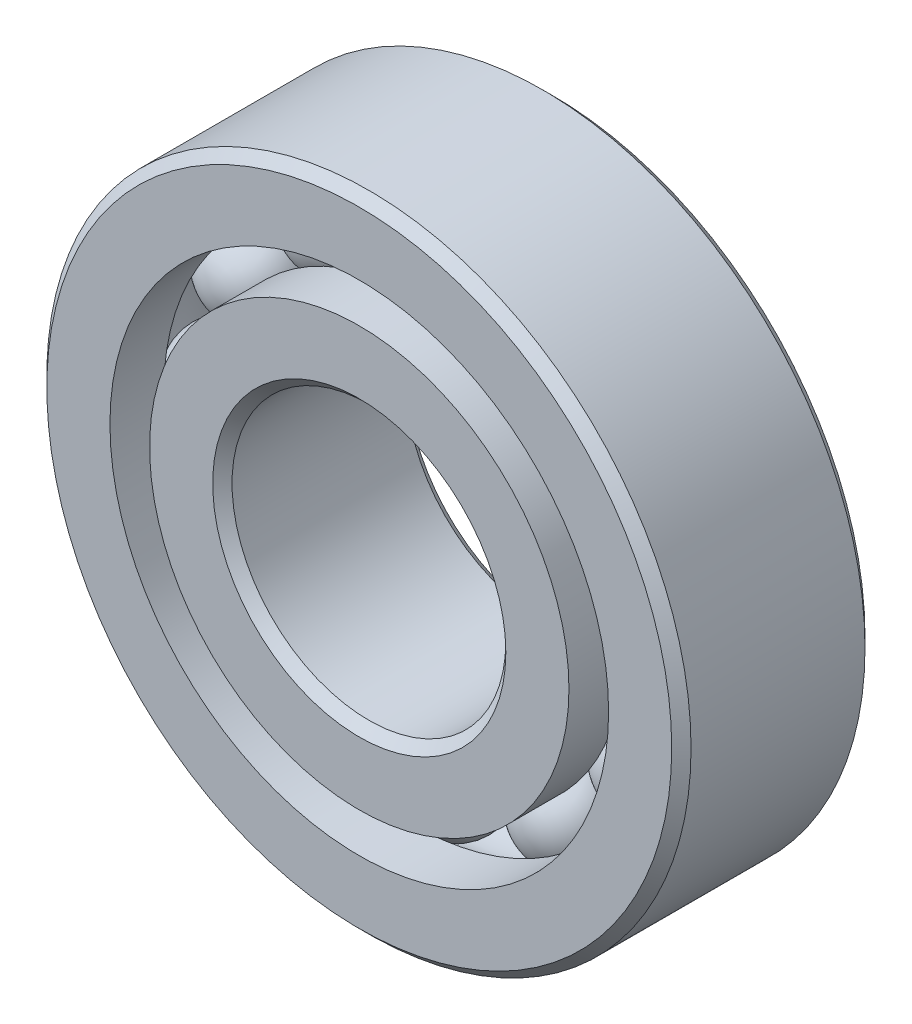
from build123d import *

# Parameters (mm, degrees)
CIRPATTERN1_COUNT = 12


with BuildPart() as part:
    # Sketch1 → Revolve1 (revolve)
    with BuildSketch(Plane(origin=(0, 0, 0), x_dir=(0, 0, -1), z_dir=(1, 0, 0))):
        with BuildLine():
            Line((5.4, 20), (-5.4, 20))
            Line((-5.4, 20), (-6, 19.4))
            Line((-6, 19.4), (-6, 15.480769231))
            Line((-6, 15.480769231), (-2.666666667, 15.480769231))
            ThreePointArc((-2.666666667, 15.480769231), (0, 17.186988936), (2.666666667, 15.480769231))
            Line((2.666666667, 15.480769231), (6, 15.480769231))
            Line((6, 15.480769231), (6, 19.4))
            Line((6, 19.4), (5.4, 20))
        make_face()
    revolve(axis=Axis((0, 0, 6), (0, 0, -1)))


with BuildPart() as body_2:
    # Sketch3 → Revolve3 (revolve)
    with BuildSketch(Plane(origin=(0, 0, 0), x_dir=(0, 0, -1), z_dir=(1, 0, 0))):
        with BuildLine():
            Line((-6, 13.019230769), (-2.666666667, 13.019230769))
            ThreePointArc((-2.666666667, 13.019230769), (0, 11.313011064), (2.666666667, 13.019230769))
            Line((2.666666667, 13.019230769), (6, 13.019230769))
            Line((6, 13.019230769), (6, 9.1))
            Line((6, 9.1), (5.4, 8.5))
            Line((5.4, 8.5), (-5.4, 8.5))
            Line((-5.4, 8.5), (-6, 9.1))
            Line((-6, 9.1), (-6, 13.019230769))
        make_face()
    revolve(axis=Axis((0, 0, 6), (0, 0, -1)))


with BuildPart() as body_3:
    # Sketch4 → Revolve4 (revolve)
    with BuildSketch(Plane(origin=(0, 0, 0), x_dir=(0, 0, -1), z_dir=(1, 0, 0))):
        with BuildLine():
            Line((-2.936988936, 14.25), (2.936988936, 14.25))
            ThreePointArc((2.936988936, 14.25), (0, 17.186988936), (-2.936988936, 14.25))
        make_face()
    revolve(axis=Axis((0, 14.25, 2.936988936), (0, 0, -1)))


with BuildPart() as cirpattern1_1:
    # CirPattern1: pattern copy
    add(body_3.part.rotate(Axis((0, 0, 0), (0, 0, 1)), 1 * 360 / CIRPATTERN1_COUNT))


with BuildPart() as cirpattern1_2:
    # CirPattern1: pattern copy
    add(body_3.part.rotate(Axis((0, 0, 0), (0, 0, 1)), 2 * 360 / CIRPATTERN1_COUNT))


with BuildPart() as cirpattern1_3:
    # CirPattern1: pattern copy
    add(body_3.part.rotate(Axis((0, 0, 0), (0, 0, 1)), 3 * 360 / CIRPATTERN1_COUNT))


with BuildPart() as cirpattern1_4:
    # CirPattern1: pattern copy
    add(body_3.part.rotate(Axis((0, 0, 0), (0, 0, 1)), 4 * 360 / CIRPATTERN1_COUNT))


with BuildPart() as cirpattern1_5:
    # CirPattern1: pattern copy
    add(body_3.part.rotate(Axis((0, 0, 0), (0, 0, 1)), 5 * 360 / CIRPATTERN1_COUNT))


with BuildPart() as cirpattern1_6:
    # CirPattern1: pattern copy
    add(body_3.part.rotate(Axis((0, 0, 0), (0, 0, 1)), 6 * 360 / CIRPATTERN1_COUNT))


with BuildPart() as cirpattern1_7:
    # CirPattern1: pattern copy
    add(body_3.part.rotate(Axis((0, 0, 0), (0, 0, 1)), 7 * 360 / CIRPATTERN1_COUNT))


with BuildPart() as cirpattern1_8:
    # CirPattern1: pattern copy
    add(body_3.part.rotate(Axis((0, 0, 0), (0, 0, 1)), 8 * 360 / CIRPATTERN1_COUNT))


with BuildPart() as cirpattern1_9:
    # CirPattern1: pattern copy
    add(body_3.part.rotate(Axis((0, 0, 0), (0, 0, 1)), 9 * 360 / CIRPATTERN1_COUNT))


with BuildPart() as cirpattern1_10:
    # CirPattern1: pattern copy
    add(body_3.part.rotate(Axis((0, 0, 0), (0, 0, 1)), 10 * 360 / CIRPATTERN1_COUNT))


with BuildPart() as cirpattern1_11:
    # CirPattern1: pattern copy
    add(body_3.part.rotate(Axis((0, 0, 0), (0, 0, 1)), 11 * 360 / CIRPATTERN1_COUNT))


solid = Compound([part.part, body_2.part, body_3.part, cirpattern1_1.part, cirpattern1_2.part, cirpattern1_3.part, cirpattern1_4.part, cirpattern1_5.part, cirpattern1_6.part, cirpattern1_7.part, cirpattern1_8.part, cirpattern1_9.part, cirpattern1_10.part, cirpattern1_11.part])
